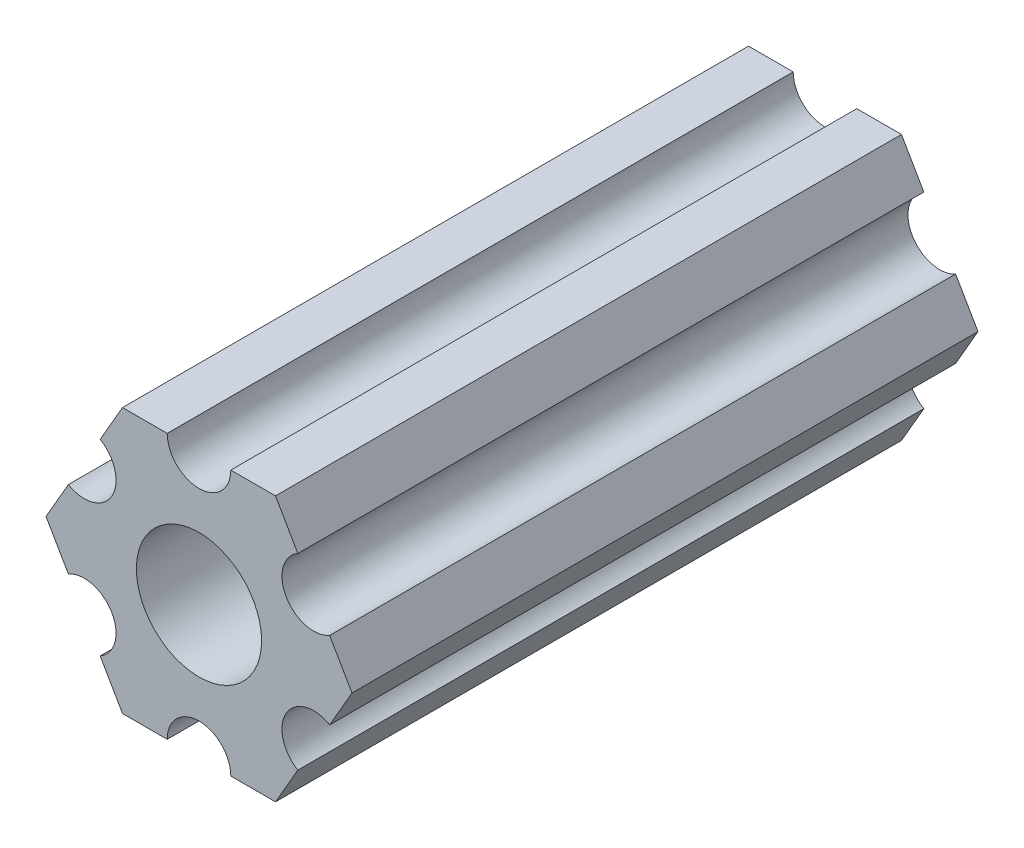
from build123d import *

# Parameters (mm, degrees)
ESBO_O1_R                = 3
RESSALTO_EXTRUS_O1_DEPTH = 30


with BuildPart() as part:
    # Esboço1 → Ressalto-extrusão1 (new body)
    with BuildSketch(Plane.XY):
        with BuildLine():
            Line((4.737261314, 4.494822715), (3.666174209, 6.35))
            Line((3.666174209, 6.35), (1.524, 6.35))
            ThreePointArc((1.524, 6.35), (0, 4.826), (-1.524, 6.35))
            Line((-1.524, 6.35), (-3.666174209, 6.35))
            Line((-3.666174209, 6.35), (-4.737261314, 4.494822715))
            ThreePointArc((-4.737261314, 4.494822715), (-4.179438599, 3.937), (-3.975261314, 3.175))
            ThreePointArc((-3.975261314, 3.175), (-4.737261314, 1.855177285), (-6.261261314, 1.855177285))
            Line((-6.261261314, 1.855177285), (-7.332348419, 0))
            Line((-7.332348419, 0), (-6.261261314, -1.855177285))
            ThreePointArc((-6.261261314, -1.855177285), (-4.737261314, -1.855177285), (-3.975261314, -3.175))
            ThreePointArc((-3.975261314, -3.175), (-4.179438599, -3.937), (-4.737261314, -4.494822715))
            Line((-4.737261314, -4.494822715), (-3.666174209, -6.35))
            Line((-3.666174209, -6.35), (-1.524, -6.35))
            ThreePointArc((-1.524, -6.35), (0, -4.826), (1.524, -6.35))
            Line((1.524, -6.35), (3.666174209, -6.35))
            Line((3.666174209, -6.35), (4.737261314, -4.494822715))
            ThreePointArc((4.737261314, -4.494822715), (4.179438599, -2.413), (6.261261314, -1.855177285))
            Line((6.261261314, -1.855177285), (7.332348419, 0))
            Line((7.332348419, 0), (6.261261314, 1.855177285))
            ThreePointArc((6.261261314, 1.855177285), (4.179438599, 2.413), (4.737261314, 4.494822715))
        make_face()
        Circle(ESBO_O1_R, mode=Mode.SUBTRACT)
    extrude(amount=RESSALTO_EXTRUS_O1_DEPTH)


solid = part.part
